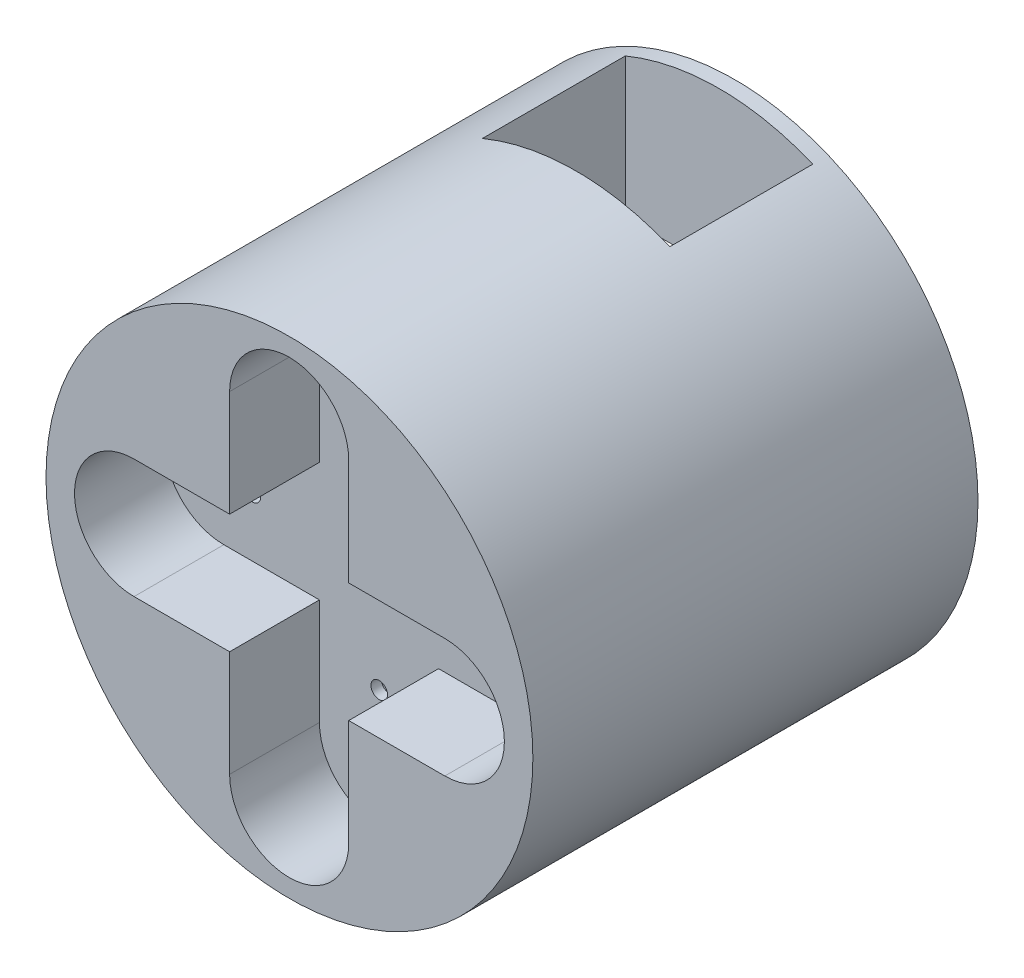
from build123d import *

# Parameters (mm, degrees)
SKETCH1_R           = 23.5
BOSS_EXTRUDE1_DEPTH = 41.47
SKETCH5_W           = 18.1
SKETCH5_H           = 47
CUT_EXTRUDE1_DEPTH  = 13.8
SKETCH6_R           = 23.5
BOSS_EXTRUDE2_DEPTH = 1.5
CUT_EXTRUDE5_DEPTH  = 1.5
CUT_EXTRUDE10_DEPTH = 8.67
SKETCH14_R          = 0.8
SKETCH14_R_2        = 0.668140713
CUT_EXTRUDE12_DEPTH = 1


with BuildPart() as part:
    # Sketch1 → Boss-Extrude1 (new body)
    with BuildSketch(Plane.XY):
        Circle(SKETCH1_R)
    extrude(amount=BOSS_EXTRUDE1_DEPTH)

    # Sketch5 → Cut-Extrude1 (cut)
    with BuildSketch(Plane(origin=(0, 0, 0), x_dir=(-1, 0, 0), z_dir=(0, 0, -1))):
        Rectangle(SKETCH5_W, SKETCH5_H)
    extrude(amount=-CUT_EXTRUDE1_DEPTH, mode=Mode.SUBTRACT)

    # Sketch6 → Boss-Extrude2 (add)
    with BuildSketch(Plane.XY):
        Circle(SKETCH6_R)
    extrude(amount=-BOSS_EXTRUDE2_DEPTH)

    # Sketch8 → Cut-Extrude5 (cut)
    with BuildSketch(Plane(origin=(0, 0, -1.5), x_dir=(-1, 0, 0), z_dir=(0, 0, -1))):
        with BuildLine():
            Line((-9.05, 8.2), (9.05, 8.2))
            Line((9.05, 8.2), (9.05, -21.687496398))
            ThreePointArc((9.05, -21.687496398), (0, -23.5), (-9.05, -21.687496398))
            Line((-9.05, -21.687496398), (-9.05, 8.2))
        make_face()
    extrude(amount=-CUT_EXTRUDE5_DEPTH, mode=Mode.SUBTRACT)

    # Sketch9 → Cut-Extrude10 (cut)
    with BuildSketch(Plane.XY.offset(41.47)):
        with BuildLine():
            Line((-5.775203881, 16), (-5.775203881, 5.75))
            Line((-5.775203881, 5.75), (-15, 5.75))
            ThreePointArc((-15, 5.75), (-20.75, 0), (-15, -5.75))
            Line((-15, -5.75), (-5.775203881, -5.75))
            Line((-5.775203881, -5.75), (-5.775203881, -16))
            ThreePointArc((-5.775203881, -16), (-0.025205722, -21.749998159), (5.724792437, -16))
            Line((5.724792437, -16), (5.724792437, -5.75))
            Line((5.724792437, -5.75), (15, -5.75))
            ThreePointArc((15, -5.75), (20.75, 0), (15, 5.75))
            Line((15, 5.75), (5.724792437, 5.75))
            Line((5.724792437, 5.75), (5.724792437, 16))
            ThreePointArc((5.724792437, 16), (-0.025205722, 21.749998159), (-5.775203881, 16))
        make_face()
    extrude(amount=-CUT_EXTRUDE10_DEPTH, mode=Mode.SUBTRACT)

    # Sketch14 → Cut-Extrude12 (cut)
    with BuildSketch(Plane.XY.offset(32.8)):
        with Locations((0, 18.949998159)):
            Circle(SKETCH14_R)
        with Locations((0, 18.949998159)):
            Circle(SKETCH14_R_2, mode=Mode.SUBTRACT)
        with Locations((0, 10.399998159)):
            Circle(SKETCH14_R)
        with Locations((0, 13.249998159)):
            Circle(SKETCH14_R)
        with Locations((0, 16.099998159)):
            Circle(SKETCH14_R)
        with Locations((0, -10.399998159)):
            Circle(SKETCH14_R)
        with Locations((0, -13.249998159)):
            Circle(SKETCH14_R)
        with Locations((0, -16.099998159)):
            Circle(SKETCH14_R)
        with Locations((0, -18.949998159)):
            Circle(SKETCH14_R)
        with Locations((12.25, 0)):
            Circle(SKETCH14_R)
        with Locations((15.1, 0)):
            Circle(SKETCH14_R)
        with Locations((17.95, 0)):
            Circle(SKETCH14_R)
        with Locations((-12.25, 0)):
            Circle(SKETCH14_R)
        with Locations((-15.1, 0)):
            Circle(SKETCH14_R)
        with Locations((-17.95, 0)):
            Circle(SKETCH14_R)
    extrude(amount=-CUT_EXTRUDE12_DEPTH, mode=Mode.SUBTRACT)


solid = part.part
